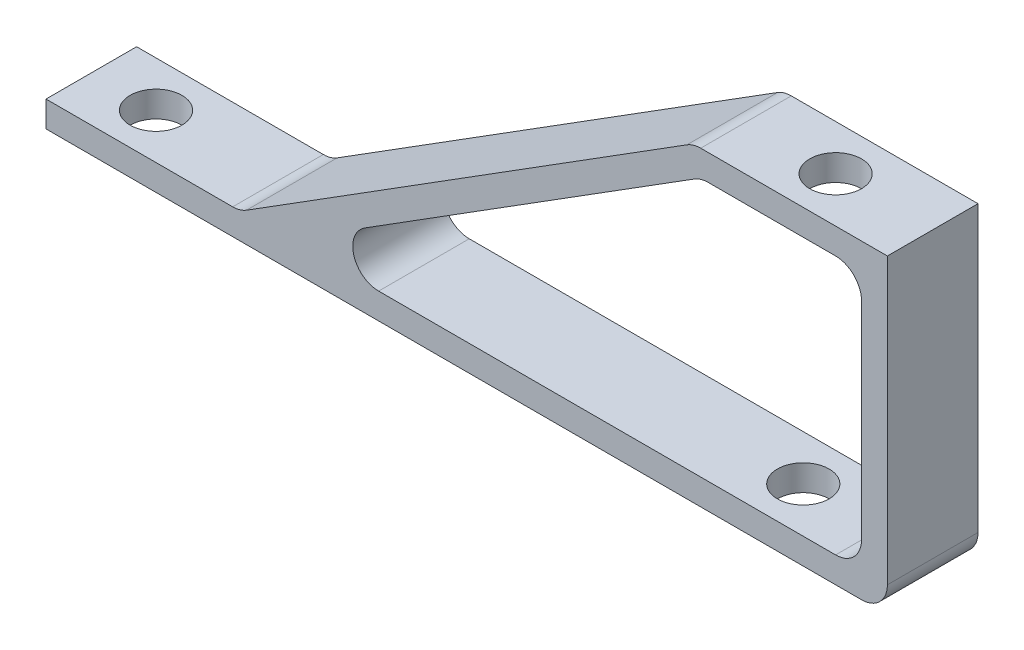
from build123d import *

# Parameters (mm, degrees)
SKETCH1_W           = 80.01
SKETCH1_H           = 8.89
SKETCH1_R           = 2.54
BOSS_EXTRUDE1_DEPTH = 2.54
SKETCH2_W           = 8.89
SKETCH2_H           = 30.48
BOSS_EXTRUDE2_DEPTH = 2.54
SKETCH3_W           = 19.05
SKETCH3_H           = 8.89
SKETCH3_R           = 2.54
BOSS_EXTRUDE3_DEPTH = 2.54
SKETCH6_W           = 52.501867586
SKETCH6_H           = 8.89
BOSS_EXTRUDE4_DEPTH = 2.54
FILLET1_R           = 2.54


with BuildPart() as part:
    # Sketch1 → Boss-Extrude1 (new body)
    with BuildSketch(Plane(origin=(0, 0, 0), x_dir=(1, 0, 0), z_dir=(0, 1, 0))):
        with Locations((-40.005, -4.445)):
            Rectangle(SKETCH1_W, SKETCH1_H)
        with Locations((-73.66, -4.445)):
            Circle(SKETCH1_R, mode=Mode.SUBTRACT)
        with Locations((-10.16, -4.445)):
            Circle(SKETCH1_R, mode=Mode.SUBTRACT)
    extrude(amount=BOSS_EXTRUDE1_DEPTH)

    # Sketch2 → Boss-Extrude2 (add)
    with BuildSketch(Plane(origin=(0, 0, 0), x_dir=(0, 0, -1), z_dir=(1, 0, 0))):
        with Locations((-4.445, 15.24)):
            Rectangle(SKETCH2_W, SKETCH2_H)
    extrude(amount=BOSS_EXTRUDE2_DEPTH)

    # Sketch3 → Boss-Extrude3 (add)
    with BuildSketch(Plane(origin=(0, 30.48, 0), x_dir=(1, 0, 0), z_dir=(0, 1, 0))):
        with Locations((-6.985, -4.445)):
            Rectangle(SKETCH3_W, SKETCH3_H)
        with Locations((-6.985, -4.445)):
            Circle(SKETCH3_R, mode=Mode.SUBTRACT)
    extrude(amount=-BOSS_EXTRUDE3_DEPTH)

    # Sketch6 → Boss-Extrude4 (add)
    with BuildSketch(Plane(origin=(-18.408683441, 29.286541837, 0), x_dir=(0.846636549, 0.532171545, 0), z_dir=(-0.532171545, 0.846636549, 0))):
        with Locations((-24.008314522, -4.445)):
            Rectangle(SKETCH6_W, SKETCH6_H)
    extrude(amount=-BOSS_EXTRUDE4_DEPTH)

    # Fillet1
    fillet1_edges = [part.edges().sort_by_distance(p)[0] for p in [
        (2.54, 0, 4.445),
        (0, 2.54, 4.445),
        (0, 27.94, 4.445),
        (-16.51, 30.48, 4.445),
        (-15.778012038, 27.94, 4.445),
        (-56.187102947, 2.54, 4.445),
        (-60.96, 2.54, 4.445),
    ]]
    fillet(fillet1_edges, radius=FILLET1_R)


solid = part.part
